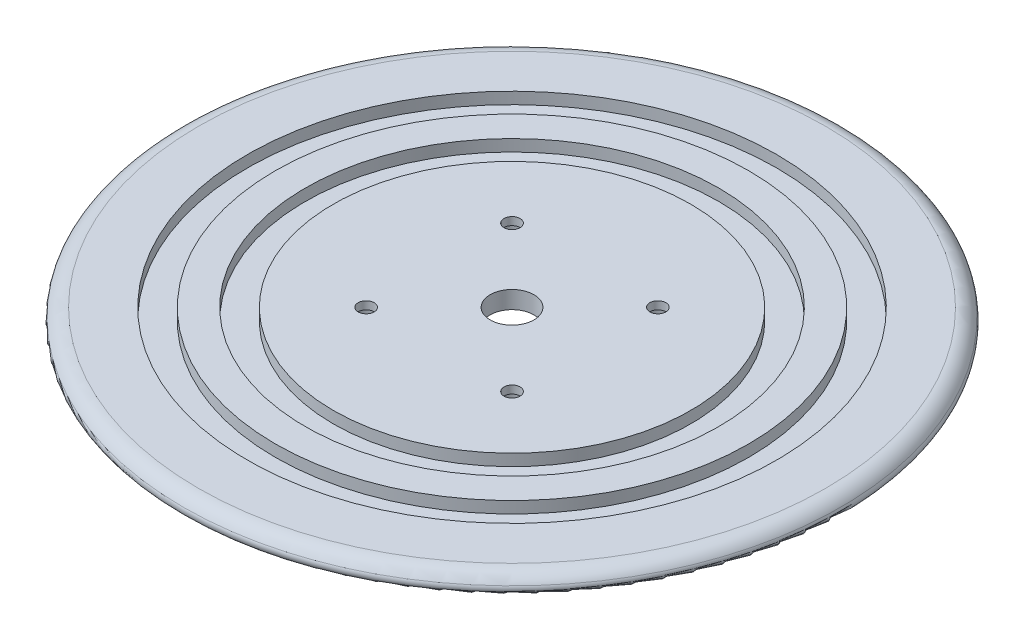
from build123d import *

# Parameters (mm, degrees)
CBORE_FOR_M5_CHEESE_HEAD_SCREW1_D           = 5.5
CBORE_FOR_M5_CHEESE_HEAD_SCREW1_CBORE_D     = 9.5
CBORE_FOR_M5_CHEESE_HEAD_SCREW1_CBORE_DEPTH = 3.3
FILLET1_R                                   = 2
SKETCH6_R                                   = 7.5
CUT_EXTRUDE1_DEPTH                          = 7.0000001


with BuildPart() as part:
    # Sketch2 → Revolve1 (revolve)
    with BuildSketch(Plane.XY):
        with BuildLine():
            Line((0, 0), (-61.26, 0))
            Line((-61.26, 0), (-61.26, -4))
            Line((-61.26, -4), (-70.86, -4))
            Line((-70.86, -4), (-70.86, 0))
            Line((-70.86, 0), (-81.13, 0))
            Line((-81.13, 0), (-81.13, -4))
            Line((-81.13, -4), (-90.73, -4))
            Line((-90.73, -4), (-90.73, 0))
            Line((-90.73, 0), (-107.5, 0))
            ThreePointArc((-107.5, 0), (-111.742640687, -1.757359313), (-113.5, -6))
            Line((-113.5, -6), (0, -6))
            Line((0, -6), (0, 0))
        make_face()
    revolve(axis=Axis((0, -6, 0), (0, 1, 0)))

    # CBORE for M5 Cheese Head Screw1 (through all)
    with Locations(Plane(origin=(0, -6, 0), x_dir=(-1, 0, 0), z_dir=(0, -1, 0))):
        with Locations((25, -25), (-25, -25), (-25, 25), (25, 25)):
            CounterBoreHole(CBORE_FOR_M5_CHEESE_HEAD_SCREW1_D / 2, CBORE_FOR_M5_CHEESE_HEAD_SCREW1_CBORE_D / 2, CBORE_FOR_M5_CHEESE_HEAD_SCREW1_CBORE_DEPTH)

    # Fillet1
    fillet1_edges = [part.edges().sort_by_distance(p)[0] for p in [
        (113.5, -6, 0),
    ]]
    fillet(fillet1_edges, radius=FILLET1_R)

    # Sketch6 → Cut-Extrude1 (cut, through all)
    with BuildSketch(Plane.XZ.offset(6)):
        Circle(SKETCH6_R)
    extrude(amount=-CUT_EXTRUDE1_DEPTH, mode=Mode.SUBTRACT)


solid = part.part
